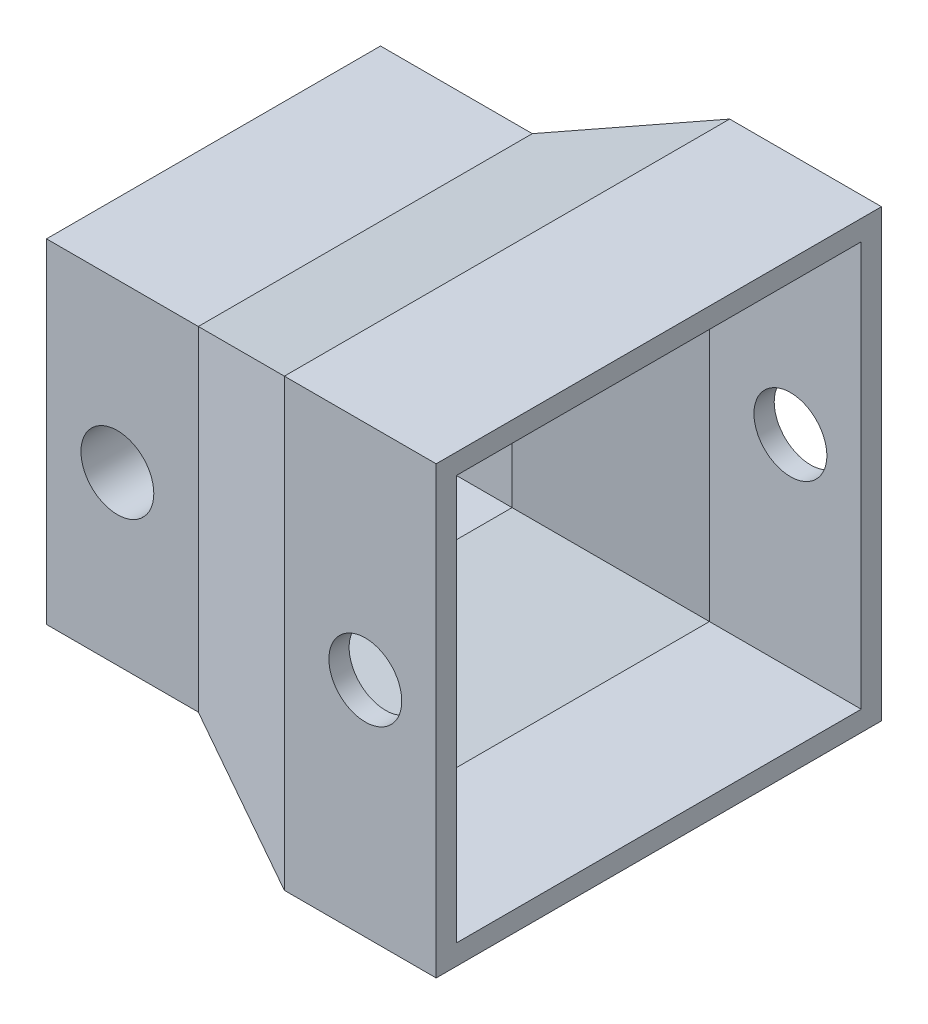
from build123d import *

# Parameters (mm, degrees)
SKETCH_1_R               = 2.5
EXTRUDE_1_DEPTH          = 1.5
SKETCH_2_R               = 3.5
EXTRUDE_2_DEPTH          = 1
SKETCH_3_R               = 2.5
EXTRUDE_3_DEPTH          = 2.5
SKETCH_4_R               = 3.5
EXTRUDE_4_DEPTH          = 1
SKETCH_5_R               = 2.5
EXTRUDE_5_DEPTH          = 2.5
SKETCH_6_R               = 3.5
EXTRUDE_6_DEPTH          = 1
SKETCH_7_R               = 2.5
EXTRUDE_7_DEPTH          = 2.5
SKETCH_10_R              = 3.5
EXTRUDE_9_DEPTH          = 1
SKETCH_11_R              = 2.5
EXTRUDE_10_DEPTH         = 1.5
SKETCH_12_R              = 1.8
CUT_EXTRUDE_2_DEPTH      = 15.5
SKETCH_13_W              = 22
SKETCH_13_H              = 22
SKETCH_13_W_2            = 20
SKETCH_13_H_2            = 20
EXTRUDE_11_DEPTH         = 3.5
EXTRUDE_11_DEPTH_BACK    = 4
SKETCH_14_W              = 16.5
SKETCH_14_H              = 16.5
SKETCH_14_W_2            = 14.5
SKETCH_14_H_2            = 14.5
EXTRUDE_12_DEPTH         = 4
EXTRUDE_12_DEPTH_BACK    = 3.5
PATTERN_CIRCULAR_1_COUNT = 4
SKETCH_19_R              = 1.8
CUT_EXTRUDE_3_DEPTH      = 20.2500001
SKETCH_20_R              = 1.8
CUT_EXTRUDE_4_DEPTH      = 23.0000001


with BuildPart() as part:
    # ｽｹｯﾁ1 → ﾎﾞｽ - 押し出し1 (new body)
    with BuildSketch(Plane.XY):
        Circle(SKETCH_1_R)
    extrude(amount=EXTRUDE_1_DEPTH)

    # ｽｹｯﾁ2 → ﾎﾞｽ - 押し出し2 (add)
    with BuildSketch(Plane.XY.offset(1.5)):
        Circle(SKETCH_2_R)
    extrude(amount=EXTRUDE_2_DEPTH)

    # ｽｹｯﾁ3 → ﾎﾞｽ - 押し出し3 (add)
    with BuildSketch(Plane.XY.offset(2.5)):
        Circle(SKETCH_3_R)
    extrude(amount=EXTRUDE_3_DEPTH)

    # ｽｹｯﾁ4 → ﾎﾞｽ - 押し出し4 (add)
    with BuildSketch(Plane.XY.offset(5)):
        Circle(SKETCH_4_R)
    extrude(amount=EXTRUDE_4_DEPTH)

    # ｽｹｯﾁ5 → ﾎﾞｽ - 押し出し5 (add)
    with BuildSketch(Plane.XY.offset(6)):
        Circle(SKETCH_5_R)
    extrude(amount=EXTRUDE_5_DEPTH)

    # ｽｹｯﾁ6 → ﾎﾞｽ - 押し出し6 (add)
    with BuildSketch(Plane.XY.offset(8.5)):
        Circle(SKETCH_6_R)
    extrude(amount=EXTRUDE_6_DEPTH)

    # ｽｹｯﾁ7 → ﾎﾞｽ - 押し出し7 (add)
    with BuildSketch(Plane.XY.offset(9.5)):
        Circle(SKETCH_7_R)
    extrude(amount=EXTRUDE_7_DEPTH)

    # ｽｹｯﾁ10 → ﾎﾞｽ - 押し出し9 (add)
    with BuildSketch(Plane.XY.offset(12)):
        Circle(SKETCH_10_R)
    extrude(amount=EXTRUDE_9_DEPTH)

    # ｽｹｯﾁ11 → ﾎﾞｽ - 押し出し10 (add)
    with BuildSketch(Plane.XY.offset(13)):
        Circle(SKETCH_11_R)
    extrude(amount=EXTRUDE_10_DEPTH)

    # ｽｹｯﾁ12 → ｶｯﾄ - 押し出し2 (cut, through all)
    with BuildSketch(Plane.XY.offset(14.5)):
        Circle(SKETCH_12_R)
    extrude(amount=-CUT_EXTRUDE_2_DEPTH, mode=Mode.SUBTRACT)

    # ｽｹｯﾁ14 → ﾎﾞｽ - 押し出し12 (add, two sides)
    with BuildSketch(Plane(origin=(0, 0, 0), x_dir=(0, 0, -1), z_dir=(1, 0, 0))) as extrude_12_sk:
        with Locations((-7.25, 0)):
            Rectangle(SKETCH_14_W, SKETCH_14_H)
        with Locations((-7.25, 0)):
            Rectangle(SKETCH_14_W_2, SKETCH_14_H_2, mode=Mode.SUBTRACT)
    extrude(amount=EXTRUDE_12_DEPTH)
    extrude(extrude_12_sk.sketch, amount=-EXTRUDE_12_DEPTH_BACK)



with BuildPart() as body_2:
    # ｽｹｯﾁ13 → ﾎﾞｽ - 押し出し11 (new body, two sides)
    with BuildSketch(Plane(origin=(15, 0, 0), x_dir=(0, 0, -1), z_dir=(1, 0, 0))) as extrude_11_sk:
        with Locations((-7.25, 0)):
            Rectangle(SKETCH_13_W, SKETCH_13_H)
        with Locations((-7.25, 0)):
            Rectangle(SKETCH_13_W_2, SKETCH_13_H_2, mode=Mode.SUBTRACT)
    extrude(amount=EXTRUDE_11_DEPTH)
    extrude(extrude_11_sk.sketch, amount=-EXTRUDE_11_DEPTH_BACK)


with BuildPart() as part_1:
    add(part.part)

    add(body_2.part)  # ﾛﾌﾄ2 merges body 2
    # ｽｹｯﾁ16 → ﾛﾌﾄ2 section 0
    with BuildSketch(Plane.ZY.offset(-11)):
        Polygon((-3.75, 11), (-2.75, 10), (17.25, 10), (18.25, 11), align=None)
    # ｽｹｯﾁ17 → ﾛﾌﾄ2 section 1
    with BuildSketch(Plane(origin=(4, 0, 0), x_dir=(0, 0, -1), z_dir=(1, 0, 0))):
        Polygon((-15.5, 8.25), (-14.5, 7.25), (0, 7.25), (1, 8.25), align=None)
    loft_2 = loft()

    # 円形ﾊﾟﾀｰﾝ1: ﾛﾌﾄ2 ×4 about axis
    pattern_circular_1_axis = Axis((0, 0, 7.25), (1, 0, 0))
    for i in range(1, PATTERN_CIRCULAR_1_COUNT):
        add(loft_2.rotate(pattern_circular_1_axis, i * 360 / PATTERN_CIRCULAR_1_COUNT))

    # ｽｹｯﾁ19 → ｶｯﾄ - 押し出し3 (cut, through all)
    with BuildSketch(Plane.XY.offset(15.5)):
        Circle(SKETCH_19_R)
    extrude(amount=-CUT_EXTRUDE_3_DEPTH, mode=Mode.SUBTRACT)

    # ｽｹｯﾁ20 → ｶｯﾄ - 押し出し4 (cut, through all)
    with BuildSketch(Plane.XY.offset(18.25)):
        with Locations((15, 0)):
            Circle(SKETCH_20_R)
    extrude(amount=-CUT_EXTRUDE_4_DEPTH, mode=Mode.SUBTRACT)


solid = part_1.part
